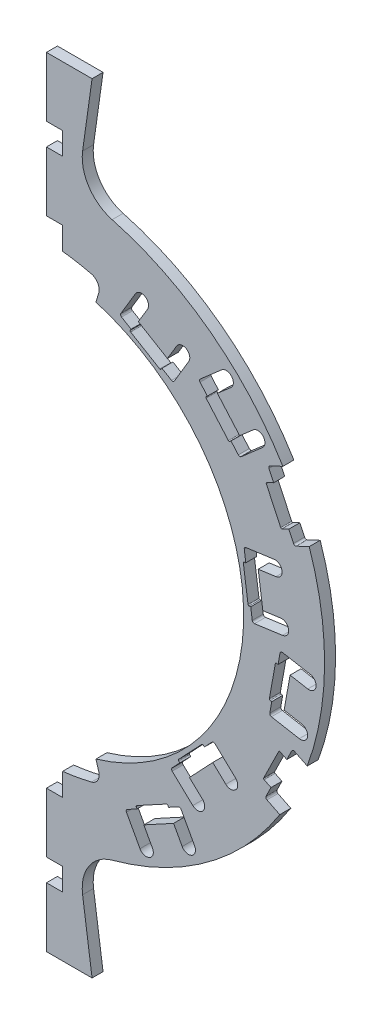
from build123d import *

# Parameters (mm, degrees)
EXTRUDE1_DEPTH                      = 2.715
F_4_40_TAPPED_HOLE2_AT_2_COUNT      = 2
F_4_40_TAPPED_HOLE2_AT_2_PITCH      = 40.5
F_4_40_TAPPED_HOLE2_AT_3_COUNT      = 2
F_4_40_TAPPED_HOLE2_AT_3_PITCH      = 81
SKETCH35_W                          = 8
SKETCH35_H                          = 11
CUT_EXTRUDE1_DEPTH                  = 6.43
EXTRUDE2_DEPTH                      = 5.43
FILLET1_R                           = 5
MOUSE_HOLE_CUT_EXTRUDE2_DEPTH       = 6.43
FILLET3_R                           = 1
LADDER_MOUNT_HOLE_EXTRUDE4_DEPTH    = 6.43
LADDER_MOUNT_HOLE_CIRPATTERN1_COUNT = 3
LADDER_MOUNT_HOLE_CIRPATTERN1_ANGLE = 102.52629862
MOUSE_HOLE_EXTRUDE3_DEPTH           = 6.43
FILLET2_R                           = 1
LADDER_MOUNT_HOLE_EXTRUDE5_DEPTH    = 6.43
LADDER_MOUNT_HOLE_CIRPATTERN2_COUNT = 2
LADDER_MOUNT_HOLE_CIRPATTERN2_ANGLE = 51.26314931
MOUSE_HOLE_CIRPATTERN3_COUNT        = 3
MOUSE_HOLE_CIRPATTERN3_ANGLE        = 102.52629862
FILLET3_OF_MOUSE_HOLE_CIRPATTERN3_R = 1
MOUSE_HOLE_CIRPATTERN4_COUNT        = 2
MOUSE_HOLE_CIRPATTERN4_ANGLE        = 51.26314931
FILLET2_OF_MOUSE_HOLE_CIRPATTERN4_R = 1


with BuildPart() as part:
    # Sketch1 → Extrude1 (new body, symmetric)
    with BuildSketch(Plane.XY):
        with BuildLine():
            Line((22.373563978, 159.196179712), (29.232493618, 208))
            Line((29.232493618, 208), (4.5, 208))
            Line((4.5, 208), (4.5, 111.909561701))
            ThreePointArc((4.5, 111.909561701), (112, 0), (4.5, -111.909561701))
            Line((4.5, -111.909561701), (4.5, -208))
            Line((4.5, -208), (29.232493618, -208))
            Line((29.232493618, -208), (22.373563978, -159.196179712))
            ThreePointArc((22.373563978, -159.196179712), (25.492385871, -145.387319735), (36.971650618, -137.102505632))
            ThreePointArc((36.971650618, -137.102505632), (142, 0), (36.971650618, 137.102505632))
            ThreePointArc((36.971650618, 137.102505632), (25.492385871, 145.387319735), (22.373563978, 159.196179712))
        make_face()
    extrude(amount=EXTRUDE1_DEPTH, both=True)

    # Sketch32 → 4-40 Tapped Hole2 (revolve, cut)
    with BuildSketch(Plane(origin=(4.5, 198, 0), x_dir=(0, 0, 1), z_dir=(0, 1, 0))):
        Polygon((0, 0), (0, 6.854664145), (1.4224, 6), (1.4224, 0), align=None)
    f_4_40_tapped_hole2 = revolve(axis=Axis((-1.85, 198, 0), (1, 0, 0)), mode=Mode.SUBTRACT)

    # 4-40 Tapped Hole2 at 2: 4-40 Tapped Hole2 ×2
    with Locations(*[(0, -i * F_4_40_TAPPED_HOLE2_AT_2_PITCH, 0) for i in range(1, F_4_40_TAPPED_HOLE2_AT_2_COUNT)]):
        add(f_4_40_tapped_hole2, mode=Mode.SUBTRACT)

    # 4-40 Tapped Hole2 at 3: 4-40 Tapped Hole2 ×2
    with Locations(*[(0, -i * F_4_40_TAPPED_HOLE2_AT_3_PITCH, 0) for i in range(1, F_4_40_TAPPED_HOLE2_AT_3_COUNT)]):
        add(f_4_40_tapped_hole2, mode=Mode.SUBTRACT)

    # Mirror1: 4-40 Tapped Hole2 across plane
    add(f_4_40_tapped_hole2.mirror(Plane.ZX), mode=Mode.SUBTRACT)

    # Mirror1 copy 1 sketch → Mirror1 copy 1 (revolve, cut)
    with BuildSketch(Plane(origin=(4.5, -157.5, 0), x_dir=(0, 0, 1), z_dir=(0, -1, 0))):
        Polygon((0, 0), (0, -6.854664145), (1.4224, -6), (1.4224, 0), align=None)
    revolve(axis=Axis((-1.85, -157.5, 0), (-1, 0, 0)), mode=Mode.SUBTRACT)

    # Mirror1 copy 2 sketch → Mirror1 copy 2 (revolve, cut)
    with BuildSketch(Plane(origin=(4.5, -117, 0), x_dir=(0, 0, 1), z_dir=(0, -1, 0))):
        Polygon((0, 0), (0, -6.854664145), (1.4224, -6), (1.4224, 0), align=None)
    revolve(axis=Axis((-1.85, -117, 0), (-1, 0, 0)), mode=Mode.SUBTRACT)

    # Sketch33 → Cut-Revolve1 (revolve, cut)
    with BuildSketch(Plane.XY):
        Polygon((11.036200376, 210.583247892), (10.543822861, 201.188125226), (12.007253004, 201.933780127), (12.456651026, 210.508805228), align=None)
    cut_revolve1 = revolve(axis=Axis((0, 0, 0), (0.052335956, 0.998629535, 0)), mode=Mode.SUBTRACT)

    # Sketch34 → Cut-Revolve2 (revolve, cut)
    with BuildSketch(Plane.XY):
        Polygon((21.99124036, 209.232675584), (21.159073235, 201.315134273), (22.477662525, 201.902208049), (23.234392729, 209.102015005), align=None)
    cut_revolve2 = revolve(axis=Axis((0, 0, 0), (0.104528463, 0.994521895, 0)), mode=Mode.SUBTRACT)

    # Mirror2: Cut-Revolve1, Cut-Revolve2 across plane
    add(cut_revolve1.mirror(Plane.ZX), mode=Mode.SUBTRACT)
    add(cut_revolve2.mirror(Plane.ZX), mode=Mode.SUBTRACT)

    # Sketch35 → Cut-Extrude1 (cut, through all)
    with BuildSketch(Plane.XY.offset(2.715)):
        with BuildLine():
            Line((4.5, 122.5), (12.5, 122.5))
            Line((12.5, 122.5), (12.5, 111.300269541))
            ThreePointArc((12.5, 111.300269541), (8.505457615, 111.676574047), (4.5, 111.909561701))
            Line((4.5, 111.909561701), (4.5, 122.5))
        make_face()
        with Locations((8.5, 157.5)):
            Rectangle(SKETCH35_W, SKETCH35_H)
        Polygon((4.5, 192.5), (27.05411068, 192.5), (29.232493618, 208), (4.5, 208), align=None)
        with BuildLine():
            Line((4.5, -122.5), (4.5, -111.909561701))
            ThreePointArc((4.5, -111.909561701), (8.505457615, -111.676574047), (12.5, -111.300269541))
            Line((12.5, -111.300269541), (12.5, -122.5))
            Line((12.5, -122.5), (4.5, -122.5))
        make_face()
        with Locations((8.5, -157.5)):
            Rectangle(SKETCH35_W, SKETCH35_H)
        Polygon((4.5, -208), (4.5, -192.5), (27.05411068, -192.5), (29.232493618, -208), align=None)
    extrude(amount=-CUT_EXTRUDE1_DEPTH, mode=Mode.SUBTRACT)

    # Sketch36 → Extrude2 (add)
    with BuildSketch(Plane.XY.offset(2.715)):
        with BuildLine():
            Line((28.96956516, -97.799612957), (31.809718607, -107.387810305))
            ThreePointArc((31.809718607, -107.387810305), (112, 0), (31.809718607, 107.387810305))
            Line((31.809718607, 107.387810305), (28.96956516, 97.799612957))
            ThreePointArc((28.96956516, 97.799612957), (102, 0), (28.96956516, -97.799612957))
        make_face()
    extrude(amount=-EXTRUDE2_DEPTH)

    # Fillet1
    fillet1_edges = [part.edges().sort_by_distance(p)[0] for p in [
        (31.809718607, -107.387810305, 0),
        (31.809718607, 107.387810305, 0),
    ]]
    fillet(fillet1_edges, radius=FILLET1_R)

    # Sketch38 → Mouse Hole Cut-Extrude2 (cut, through all)
    with BuildSketch(Plane.XY.offset(2.715)):
        with BuildLine():
            Line((79.789058848, 90.023565589), (84.391221028, 84.749089001))
            Line((84.391221028, 84.749089001), (95.693670858, 94.610865101))
            ThreePointArc((95.693670858, 94.610865101), (96.029828062, 99.549184485), (91.091508678, 99.885341688))
            Line((91.091508678, 99.885341688), (79.789058848, 90.023565589))
        make_face()
        with BuildLine():
            Line((74.866517297, 95.353430289), (67.174381022, 82.47589017))
            Line((67.174381022, 82.47589017), (61.164862299, 86.065553765))
            Line((61.164862299, 86.065553765), (68.856998574, 98.943093884))
            ThreePointArc((68.856998574, 98.943093884), (73.656589733, 100.153021448), (74.866517297, 95.353430289))
        make_face()
        with BuildLine():
            Line((95.403537673, 72.128020025), (106.705987503, 81.989796124))
            ThreePointArc((106.705987503, 81.989796124), (111.644306887, 81.653638921), (111.308149683, 76.715319537))
            Line((111.308149683, 76.715319537), (100.005699853, 66.853543437))
            Line((100.005699853, 66.853543437), (95.403537673, 72.128020025))
        make_face()
        with BuildLine():
            Line((40.775423777, 98.244769534), (46.784942499, 94.655105938))
            Line((46.784942499, 94.655105938), (54.477078774, 107.532646058))
            ThreePointArc((54.477078774, 107.532646058), (53.267151211, 112.332237217), (48.467560052, 111.122309653))
            Line((48.467560052, 111.122309653), (40.775423777, 98.244769534))
        make_face()
    mouse_hole_cut_extrude2 = extrude(amount=-MOUSE_HOLE_CUT_EXTRUDE2_DEPTH, mode=Mode.SUBTRACT)

    # Fillet3
    fillet3_edges = [part.edges().sort_by_distance(p)[0] for p in [
        (40.775423777, 98.244769534, 0),
        (67.174381022, 82.47589017, 0),
        (79.789058848, 90.023565589, 0),
        (100.005699853, 66.853543437, 0),
    ]]
    fillet(fillet3_edges, radius=FILLET3_R)

    # Sketch40 → Ladder Mount Hole Extrude4 (cut, through all)
    with BuildSketch(Plane.XY.offset(2.715)):
        with BuildLine():
            Line((46.131110916, 93.560515028), (60.511030716, 84.970962854))
            ThreePointArc((60.511030716, 84.970962854), (60.889656399, 84.91538227), (61.196686596, 85.143809649))
            Line((61.196686596, 85.143809649), (64.735069282, 91.067478104))
            Line((64.735069282, 91.067478104), (49.496646808, 100.169839363))
            Line((49.496646808, 100.169839363), (45.958264121, 94.246170908))
            ThreePointArc((45.958264121, 94.246170908), (45.902683536, 93.867545225), (46.131110916, 93.560515028))
        make_face()
        with BuildLine():
            Line((95.148303635, 71.241746599), (100.347430557, 75.778163604))
            Line((100.347430557, 75.778163604), (88.677662172, 89.152729236))
            Line((88.677662172, 89.152729236), (83.47853525, 84.616312231))
            ThreePointArc((83.47853525, 84.616312231), (83.308415531, 84.273520908), (83.430512793, 83.910838033))
            Line((83.430512793, 83.910838033), (94.442829438, 71.289769056))
            ThreePointArc((94.442829438, 71.289769056), (94.78562076, 71.119649337), (95.148303635, 71.241746599))
        make_face()
    ladder_mount_hole_extrude4 = extrude(amount=-LADDER_MOUNT_HOLE_EXTRUDE4_DEPTH, mode=Mode.SUBTRACT)

    # Ladder Mount Hole CirPattern1: Ladder Mount Hole Extrude4 ×3 about axis
    ladder_mount_hole_cirpattern1_axis = Axis((0, 0, 0), (0, 0, -1))
    for i in range(1, LADDER_MOUNT_HOLE_CIRPATTERN1_COUNT):
        add(ladder_mount_hole_extrude4.rotate(ladder_mount_hole_cirpattern1_axis, i * LADDER_MOUNT_HOLE_CIRPATTERN1_ANGLE / (LADDER_MOUNT_HOLE_CIRPATTERN1_COUNT - 1)), mode=Mode.SUBTRACT)

    # Sketch39 → Mouse Hole Extrude3 (cut, through all)
    with BuildSketch(Plane.XY.offset(2.715)):
        with BuildLine():
            Line((127.089215564, 42.424279383), (124.125444221, 48.765892697))
            Line((124.125444221, 48.765892697), (131.966156779, 52.43027241))
            ThreePointArc((131.966156779, 52.43027241), (133.22262306, 49.150103815), (134.39757133, 45.839860608))
            Line((134.39757133, 45.839860608), (127.089215564, 42.424279383))
        make_face()
        with BuildLine():
            Line((114.069791453, 70.282080729), (121.37814722, 73.697661954))
            ThreePointArc((121.37814722, 73.697661954), (123.163892858, 70.672876666), (124.874275353, 67.604847127))
            Line((124.874275353, 67.604847127), (117.033562795, 63.940467414))
            Line((117.033562795, 63.940467414), (114.069791453, 70.282080729))
        make_face()
    mouse_hole_extrude3 = extrude(amount=-MOUSE_HOLE_EXTRUDE3_DEPTH, mode=Mode.SUBTRACT)

    # Fillet2
    fillet2_edges = [part.edges().sort_by_distance(p)[0] for p in [
        (114.069791453, 70.282080729, 0),
        (127.089215564, 42.424279383, 0),
    ]]
    fillet(fillet2_edges, radius=FILLET2_R)

    # Sketch41 → Ladder Mount Hole Extrude5 (cut, through all)
    with BuildSketch(Plane.XY.offset(2.715)):
        with BuildLine():
            Line((131.10003092, 71.066382047), (138.615308252, 54.98586257))
            Line((138.615308252, 54.98586257), (120.949385447, 46.729642403))
            ThreePointArc((120.949385447, 46.729642403), (120.567080711, 46.712621883), (120.284715114, 46.970916829))
            Line((120.284715114, 46.970916829), (113.192833688, 62.145491546))
            ThreePointArc((113.192833688, 62.145491546), (113.175813168, 62.527796283), (113.434108115, 62.810161879))
            Line((113.434108115, 62.810161879), (131.10003092, 71.066382047))
        make_face()
    ladder_mount_hole_extrude5 = extrude(amount=-LADDER_MOUNT_HOLE_EXTRUDE5_DEPTH, mode=Mode.SUBTRACT)

    # Ladder Mount Hole CirPattern2: Ladder Mount Hole Extrude5 ×2 about axis
    ladder_mount_hole_cirpattern2_axis = Axis((0, 0, 0), (0, 0, -1))
    for i in range(1, LADDER_MOUNT_HOLE_CIRPATTERN2_COUNT):
        add(ladder_mount_hole_extrude5.rotate(ladder_mount_hole_cirpattern2_axis, i * LADDER_MOUNT_HOLE_CIRPATTERN2_ANGLE / (LADDER_MOUNT_HOLE_CIRPATTERN2_COUNT - 1)), mode=Mode.SUBTRACT)

    # Mouse Hole CirPattern3: Mouse Hole Cut-Extrude2 ×3 about axis
    mouse_hole_cirpattern3_axis = Axis((0, 0, 0), (0, 0, -1))
    for i in range(1, MOUSE_HOLE_CIRPATTERN3_COUNT):
        add(mouse_hole_cut_extrude2.rotate(mouse_hole_cirpattern3_axis, i * MOUSE_HOLE_CIRPATTERN3_ANGLE / (MOUSE_HOLE_CIRPATTERN3_COUNT - 1)), mode=Mode.SUBTRACT)

    # Fillet3 of Mouse Hole CirPattern3
    fillet3_of_mouse_hole_cirpattern3_edges = [part.edges().sort_by_distance(p)[0] for p in [
        (102.148678086, 29.670144762, 0),
        (106.367510493, -0.789073105, 0),
        (120.148474426, -5.905960245, 0),
        (114.725657185, -36.174021848, 0),
        (87.062517734, -61.112911326, 0),
        (65.943382614, -83.463406439, 0),
        (70.575428818, -97.414809553, 0),
        (43.572191979, -112.124931926, 0),
    ]]
    fillet(fillet3_of_mouse_hole_cirpattern3_edges, radius=FILLET3_OF_MOUSE_HOLE_CIRPATTERN3_R)

    # Mouse Hole CirPattern4: Mouse Hole Extrude3 ×2 about axis
    mouse_hole_cirpattern4_axis = Axis((0, 0, 0), (0, 0, -1))
    for i in range(1, MOUSE_HOLE_CIRPATTERN4_COUNT):
        add(mouse_hole_extrude3.rotate(mouse_hole_cirpattern4_axis, i * MOUSE_HOLE_CIRPATTERN4_ANGLE / (MOUSE_HOLE_CIRPATTERN4_COUNT - 1)), mode=Mode.SUBTRACT)

    # Fillet2 of Mouse Hole CirPattern4
    fillet2_of_mouse_hole_cirpattern4_edges = [part.edges().sort_by_distance(p)[0] for p in [
        (126.200540242, -44.999020394, 0),
        (112.617504757, -72.586402419, 0),
    ]]
    fillet(fillet2_of_mouse_hole_cirpattern4_edges, radius=FILLET2_OF_MOUSE_HOLE_CIRPATTERN4_R)


solid = part.part
